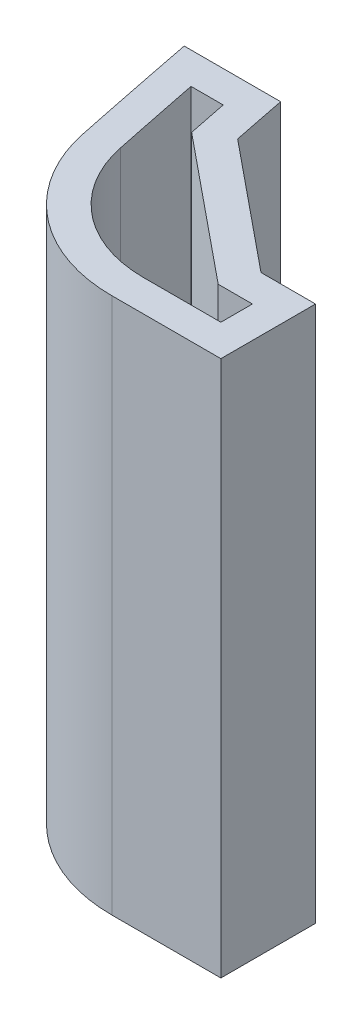
from build123d import *

# Parameters (mm, degrees)
BOSS_EXTRUDE1_DEPTH = 17
SKETCH4_R           = 1.6
CUT_EXTRUDE2_DEPTH  = 1


with BuildPart() as part:
    # Sketch1 → Boss-Extrude1 (new body)
    with BuildSketch(Plane(origin=(0, 0, 0), x_dir=(1, 0, 0), z_dir=(0, 1, 0))):
        with BuildLine():
            Line((1.322591209, -4.028579324), (4.779691323, -4.028579324))
            Line((4.779691323, -4.028579324), (4.779691323, -1.028579324))
            Line((4.779691323, -1.028579324), (3.051141266, -1.028579324))
            Line((3.051141266, -1.028579324), (-0.984859984, 2.26705444))
            ThreePointArc((-0.984859984, 2.26705444), (-1.156228622, 3.119019075), (-1.325410362, 3.971420676))
            Line((-1.325410362, 3.971420676), (-4.382631249, 3.971420676))
            ThreePointArc((-4.382631249, 3.971420676), (-3.983741211, 1.961503644), (-3.572803177, -0.045984755))
            ThreePointArc((-3.572803177, -0.045984755), (-1.83279885, -2.907176181), (1.322591209, -4.028579324))
        make_face()
        with BuildLine():
            Line((3.779691323, -3.028579324), (3.779691323, -2.028579324))
            Line((3.779691323, -2.028579324), (2.694726151, -2.028579324))
            Line((2.694726151, -2.028579324), (-1.893840411, 1.718256703))
            ThreePointArc((-1.893840411, 1.718256703), (-2.020759818, 2.344719816), (-2.146500023, 2.971420676))
            Line((-2.146500023, 2.971420676), (-3.166177568, 2.971420676))
            ThreePointArc((-3.166177568, 2.971420676), (-2.882916081, 1.563855286), (-2.5937243, 0.157496332))
            ThreePointArc((-2.5937243, 0.157496332), (-1.201720839, -2.131456809), (1.322591209, -3.028579324))
            Line((1.322591209, -3.028579324), (3.779691323, -3.028579324))
        make_face(mode=Mode.SUBTRACT)
    extrude(amount=BOSS_EXTRUDE1_DEPTH)

    # Sketch4 → Cut-Extrude2 (cut)
    with BuildSketch(Plane(origin=(0.716662117, 0, -0.877660993), x_dir=(-0.774572925, 0, -0.632484612), z_dir=(0.632484612, 0, -0.774572925))):
        with Locations((-0.408584542, 8.5)):
            Circle(SKETCH4_R)
    extrude(amount=-CUT_EXTRUDE2_DEPTH, mode=Mode.SUBTRACT)


solid = part.part
